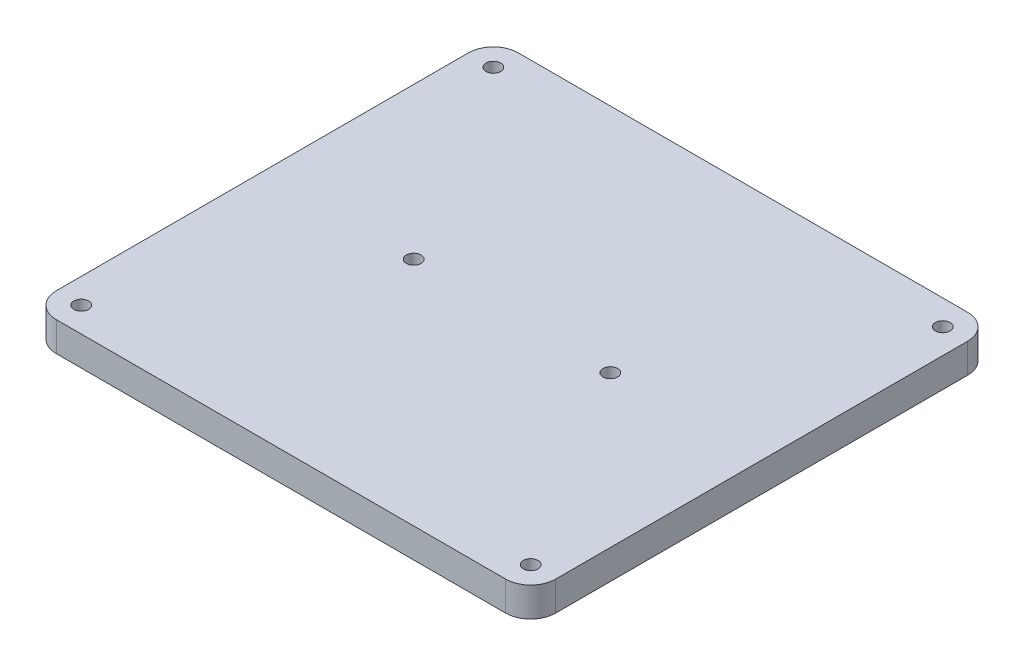
from build123d import *

# Parameters (mm, degrees)
SKETCH1_W           = 50.8
SKETCH1_H           = 47
SKETCH1_R           = 0.75
BOSS_EXTRUDE1_DEPTH = 3
FILLET1_R           = 2.54


with BuildPart() as part:
    # Sketch1 → Boss-Extrude1 (new body)
    with BuildSketch(Plane(origin=(0, 0, 0), x_dir=(1, 0, 0), z_dir=(0, 1, 0))):
        Rectangle(SKETCH1_W, SKETCH1_H)
        with Locations((-22.86, 20.96)):
            Circle(SKETCH1_R, mode=Mode.SUBTRACT)
        with Locations((22.86, 20.96)):
            Circle(SKETCH1_R, mode=Mode.SUBTRACT)
        with Locations((22.86, -20.96)):
            Circle(SKETCH1_R, mode=Mode.SUBTRACT)
        with Locations((-22.86, -20.96)):
            Circle(SKETCH1_R, mode=Mode.SUBTRACT)
        with Locations((10, 0)):
            Circle(SKETCH1_R, mode=Mode.SUBTRACT)
        with Locations((-10, 0)):
            Circle(SKETCH1_R, mode=Mode.SUBTRACT)
    extrude(amount=BOSS_EXTRUDE1_DEPTH)

    # Fillet1
    fillet1_edges = [part.edges().sort_by_distance(p)[0] for p in [
        (-25.4, 1.5, -23.5),
        (25.4, 1.5, -23.5),
        (25.4, 1.5, 23.5),
        (-25.4, 1.5, 23.5),
    ]]
    fillet(fillet1_edges, radius=FILLET1_R)


solid = part.part
